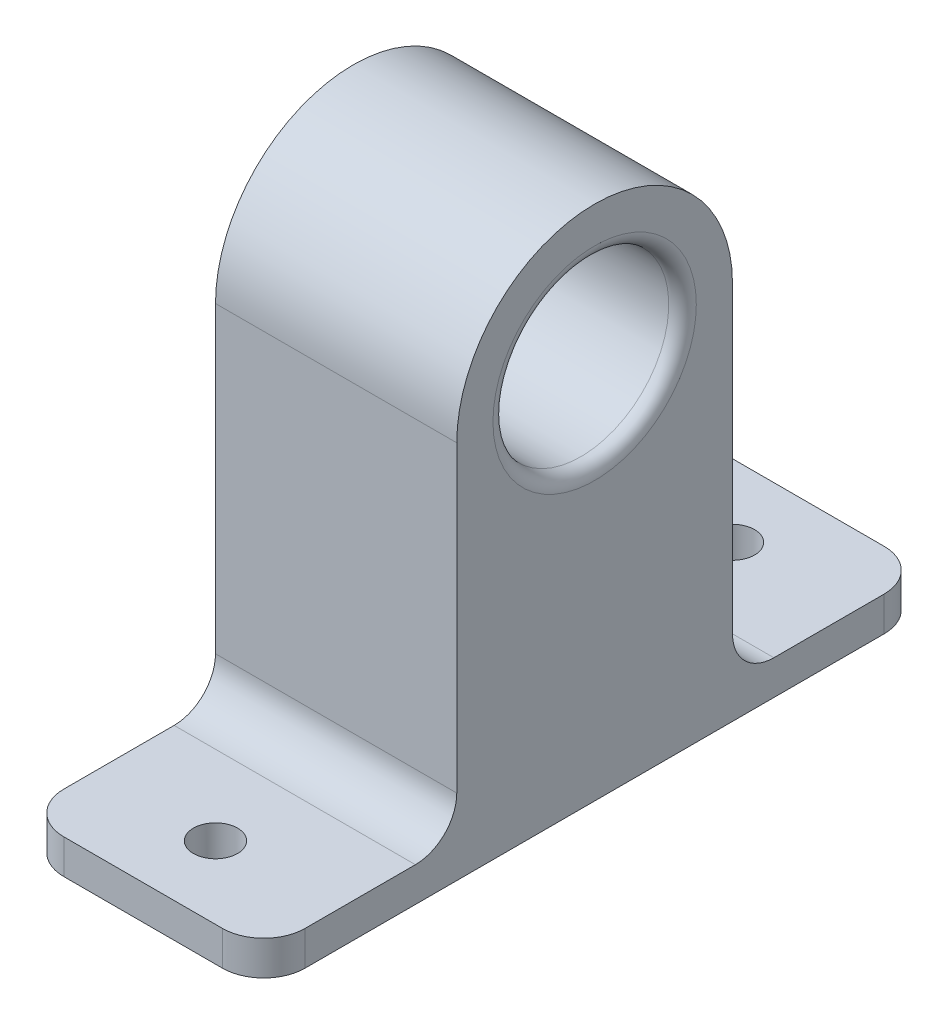
from build123d import *

# Parameters (mm, degrees)
BOSS_EXTRUDE1_DEPTH = 35
SKETCH2_R           = 12.75
CUT_EXTRUDE1_DEPTH  = 32
CUT_EXTRUDE2_REACH  = 37
SKETCH3_R           = 1.5
SKETCH3_R_2         = 3.75
CUT_EXTRUDE3_REACH  = 7
SKETCH4_R           = 3.2
FILLET1_R           = 2
FILLET3_R           = 6
FILLET4_R           = 6


with BuildPart() as part:
    # Sketch1 → Boss-Extrude1 (new body)
    with BuildSketch(Plane(origin=(0, 0, 0), x_dir=(0, 0, -1), z_dir=(1, 0, 0))):
        with BuildLine():
            Line((-48, -55), (-48, -50))
            Line((-48, -50), (-20, -50))
            Line((-20, -50), (-20, 0))
            ThreePointArc((-20, 0), (0, 20), (20, 0))
            Line((20, 0), (20, -50))
            Line((20, -50), (48, -50))
            Line((48, -50), (48, -55))
            Line((48, -55), (-48, -55))
        make_face()
    extrude(amount=BOSS_EXTRUDE1_DEPTH)

    # Sketch2 → Cut-Extrude1 (cut)
    with BuildSketch(Plane(origin=(35, 0, 0), x_dir=(0, 0, -1), z_dir=(1, 0, 0))):
        Circle(SKETCH2_R)
    extrude(amount=-CUT_EXTRUDE1_DEPTH, mode=Mode.SUBTRACT)

    # Sketch3 → Cut-Extrude2 (cut, up to next)
    with BuildSketch(Plane.ZY, mode=Mode.PRIVATE) as cut_extrude2_sk1:
        with Locations((0, 8.5)):
            Circle(SKETCH3_R)
    cut_extrude2_tool1 = extrude(cut_extrude2_sk1.sketch, amount=-CUT_EXTRUDE2_REACH, mode=Mode.PRIVATE) & part.part
    add(cut_extrude2_tool1.solids().sort_by_distance((0, 8.5, 0))[0], mode=Mode.SUBTRACT)
    # Sketch3 → Cut-Extrude2 (cut, up to next)
    with BuildSketch(Plane.ZY, mode=Mode.PRIVATE) as cut_extrude2_sk2:
        with Locations((0, -8.5)):
            Circle(SKETCH3_R)
    cut_extrude2_tool2 = extrude(cut_extrude2_sk2.sketch, amount=-CUT_EXTRUDE2_REACH, mode=Mode.PRIVATE) & part.part
    add(cut_extrude2_tool2.solids().sort_by_distance((0, -8.5, 0))[0], mode=Mode.SUBTRACT)
    # Sketch3 → Cut-Extrude2 (cut, up to next)
    with BuildSketch(Plane.ZY, mode=Mode.PRIVATE) as cut_extrude2_sk3:
        Circle(SKETCH3_R_2)
    cut_extrude2_tool3 = extrude(cut_extrude2_sk3.sketch, amount=-CUT_EXTRUDE2_REACH, mode=Mode.PRIVATE) & part.part
    add(cut_extrude2_tool3.solids().sort_by_distance((0, 0, 0))[0], mode=Mode.SUBTRACT)

    # Sketch4 → Cut-Extrude3 (cut, up to next)
    with BuildSketch(Plane(origin=(0, -50, 0), x_dir=(1, 0, 0), z_dir=(0, 1, 0)), mode=Mode.PRIVATE) as cut_extrude3_sk1:
        with Locations((17.5, 37.5)):
            Circle(SKETCH4_R)
    cut_extrude3_tool1 = extrude(cut_extrude3_sk1.sketch, amount=-CUT_EXTRUDE3_REACH, mode=Mode.PRIVATE) & part.part
    add(cut_extrude3_tool1.solids().sort_by_distance((17.5, -50, -37.5))[0], mode=Mode.SUBTRACT)
    # Sketch4 → Cut-Extrude3 (cut, up to next)
    with BuildSketch(Plane(origin=(0, -50, 0), x_dir=(1, 0, 0), z_dir=(0, 1, 0)), mode=Mode.PRIVATE) as cut_extrude3_sk2:
        with Locations((17.5, -37.5)):
            Circle(SKETCH4_R)
    cut_extrude3_tool2 = extrude(cut_extrude3_sk2.sketch, amount=-CUT_EXTRUDE3_REACH, mode=Mode.PRIVATE) & part.part
    add(cut_extrude3_tool2.solids().sort_by_distance((17.5, -50, 37.5))[0], mode=Mode.SUBTRACT)

    # Fillet1
    fillet1_edges = [part.edges().sort_by_distance(p)[0] for p in [
        (35, 0, 12.75),
    ]]
    fillet(fillet1_edges, radius=FILLET1_R)

    # Fillet3
    fillet3_edges = [part.edges().sort_by_distance(p)[0] for p in [
        (17.5, -50, 20),
        (17.5, -50, -20),
    ]]
    fillet(fillet3_edges, radius=FILLET3_R)

    # Fillet4
    fillet4_edges = [part.edges().sort_by_distance(p)[0] for p in [
        (0, -52.5, -48),
        (35, -52.5, 48),
        (0, -52.5, 48),
        (35, -52.5, -48),
    ]]
    fillet(fillet4_edges, radius=FILLET4_R)


solid = part.part
